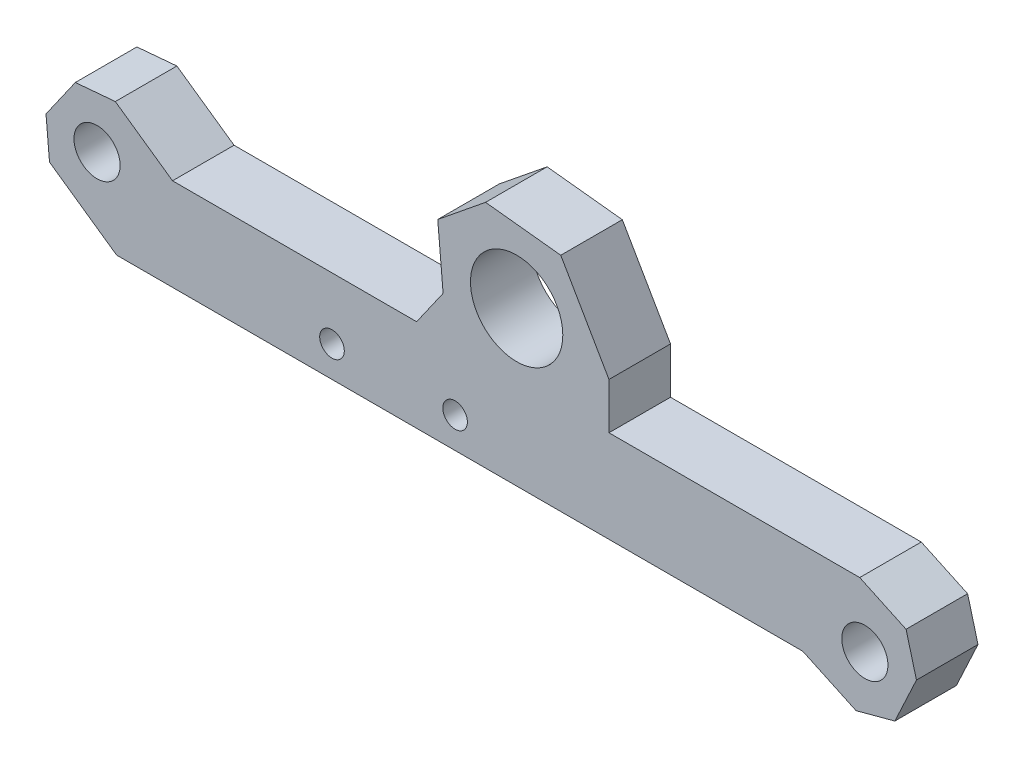
from build123d import *

# Parameters (mm, degrees)
SKETCH_1_R             = 3
SKETCH_1_R_2           = 1.5
EXTRUDE_1_DEPTH        = 4
HOLE_WIZARD_M2_1_D     = 1.6
HOLE_WIZARD_M2_1_DEPTH = 14
HOLE_WIZARD_M2_1_TIP   = 0.480688495
CHAMFER_1_SIZE         = 2
CHAMFER_1_SIZE2        = 1.678199262
CHAMFER_1_PART_2_SIZE  = 2
CHAMFER_1_PART_2_SIZE2 = 1.678199262
CHAMFER_1_PART_3_SIZE  = 2
CHAMFER_1_PART_3_SIZE2 = 1.678199262
CHAMFER_1_PART_4_SIZE  = 2
CHAMFER_1_PART_4_SIZE2 = 1.678199262


with BuildPart() as part:
    # 草图1 → 凸台-拉伸1 (new body)
    with BuildSketch(Plane.XY):
        Polygon((0, 0), (44.599947574, 0), (49.869528236, -2.457245818), (52.827856068, 3.886908691), (48.296317133, 6), (32, 6), (32, 9), (28.867245682, 14.426089647), (23.980690184, 14.959516489), (20.872106338, 12.442234925), (21.220729309, 8.457456133), (19.5, 6), (3.635239529, 6), (-1.719029256, 9.749099364), (-5.73406431, 4.015035054), align=None)
        with Locations((26, 10)):
            Circle(SKETCH_1_R, mode=Mode.SUBTRACT)
        with Locations((-1.26909065, 5.1613379)):
            Circle(SKETCH_1_R_2, mode=Mode.SUBTRACT)
        with Locations((48.629768791, 1.982686222)):
            Circle(SKETCH_1_R_2, mode=Mode.SUBTRACT)
    extrude(amount=EXTRUDE_1_DEPTH)

    # M2 螺纹孔1
    with Locations(Plane.XY.offset(4)):
        with Locations((14, 2), (22, 2)):
            Hole(HOLE_WIZARD_M2_1_D / 2, depth=HOLE_WIZARD_M2_1_DEPTH)
            with Locations((0, 0, -(HOLE_WIZARD_M2_1_DEPTH + HOLE_WIZARD_M2_1_TIP / 2))):  # 118° drill point
                Cone(0, HOLE_WIZARD_M2_1_D / 2, HOLE_WIZARD_M2_1_TIP, mode=Mode.SUBTRACT)

    # 倒角1
    chamfer_1_edges = [part.edges().sort_by_distance(p)[0] for p in [
        (-5.73406431, 4.015035054, 2),
    ]]
    chamfer_1_side = [part.faces().sort_by_distance(p)[0] for p in [
        (-3.726546783, 6.882067209, 2),
    ]]
    chamfer(chamfer_1_edges, length=CHAMFER_1_SIZE, length2=CHAMFER_1_SIZE2, reference=chamfer_1_side[0])

    # 倒角1 part 2
    chamfer_1_part_2_edges = [part.edges().sort_by_distance(p)[0] for p in [
        (-1.719029256, 9.749099364, 2),
    ]]
    chamfer_1_part_2_side = [part.faces().sort_by_distance(p)[0] for p in [
        (0.958105137, 7.874549682, 2),
    ]]
    chamfer(chamfer_1_part_2_edges, length=CHAMFER_1_PART_2_SIZE, length2=CHAMFER_1_PART_2_SIZE2, reference=chamfer_1_part_2_side[0])

    # 倒角1 part 3
    chamfer_1_part_3_edges = [part.edges().sort_by_distance(p)[0] for p in [
        (52.827856068, 3.886908691, 2),
    ]]
    chamfer_1_part_3_side = [part.faces().sort_by_distance(p)[0] for p in [
        (51.348692152, 0.714831437, 2),
    ]]
    chamfer(chamfer_1_part_3_edges, length=CHAMFER_1_PART_3_SIZE, length2=CHAMFER_1_PART_3_SIZE2, reference=chamfer_1_part_3_side[0])

    # 倒角1 part 4
    chamfer_1_part_4_edges = [part.edges().sort_by_distance(p)[0] for p in [
        (49.869528236, -2.457245818, 2),
    ]]
    chamfer_1_part_4_side = [part.faces().sort_by_distance(p)[0] for p in [
        (47.234737905, -1.228622909, 2),
    ]]
    chamfer(chamfer_1_part_4_edges, length=CHAMFER_1_PART_4_SIZE, length2=CHAMFER_1_PART_4_SIZE2, reference=chamfer_1_part_4_side[0])


solid = part.part
